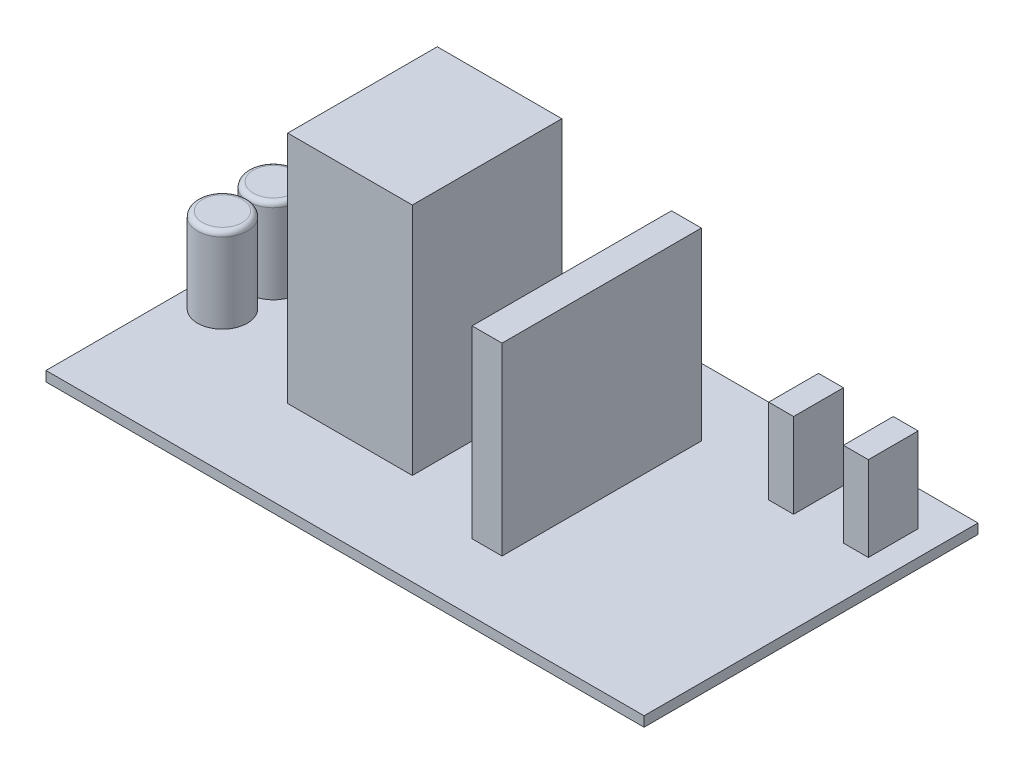
from build123d import *

# Parameters (mm, degrees)
SKETCH1_W           = 120
SKETCH1_H           = 67
BOSS_EXTRUDE1_DEPTH = 2
SKETCH2_R           = 5
BOSS_EXTRUDE2_DEPTH = 17
FILLET1_R           = 1
SKETCH3_W           = 25
SKETCH3_H           = 30
BOSS_EXTRUDE3_DEPTH = 47
SKETCH3_3_W         = 6
SKETCH3_3_H         = 40
BOSS_EXTRUDE4_DEPTH = 37
SKETCH3_4_W         = 5
SKETCH3_4_H         = 10
BOSS_EXTRUDE5_DEPTH = 17


with BuildPart() as part:
    # Sketch1 → Boss-Extrude1 (new body)
    with BuildSketch(Plane(origin=(0, 0, 0), x_dir=(1, 0, 0), z_dir=(0, 1, 0))):
        Rectangle(SKETCH1_W, SKETCH1_H)
    extrude(amount=BOSS_EXTRUDE1_DEPTH)

    # Sketch2 → Boss-Extrude2 (add)
    with BuildSketch(Plane(origin=(0, 2, 0), x_dir=(1, 0, 0), z_dir=(0, 1, 0))):
        with Locations((-53, 5.1)):
            Circle(SKETCH2_R)
        with Locations((-53, -5.1)):
            Circle(SKETCH2_R)
    extrude(amount=BOSS_EXTRUDE2_DEPTH)

    # Fillet1
    fillet1_edges = [part.edges().sort_by_distance(p)[0] for p in [
        (-58, 19, 5.1),
        (-58, 19, -5.1),
    ]]
    fillet(fillet1_edges, radius=FILLET1_R)

    # Sketch3 → Boss-Extrude3 (add)
    with BuildSketch(Plane(origin=(0, 2, 0), x_dir=(1, 0, 0), z_dir=(0, 1, 0))):
        with Locations((-17.5, 0)):
            Rectangle(SKETCH3_W, SKETCH3_H)
    extrude(amount=BOSS_EXTRUDE3_DEPTH)

    # Sketch3_3 → Boss-Extrude4 (add)
    with BuildSketch(Plane(origin=(0, 2, 0), x_dir=(1, 0, 0), z_dir=(0, 1, 0))):
        with Locations((15, 0)):
            Rectangle(SKETCH3_3_W, SKETCH3_3_H)
    extrude(amount=BOSS_EXTRUDE4_DEPTH)

    # Sketch3_4 → Boss-Extrude5 (add)
    with BuildSketch(Plane(origin=(0, 2, 0), x_dir=(1, 0, 0), z_dir=(0, 1, 0))):
        with Locations((52.5, 21.5)):
            Rectangle(SKETCH3_4_W, SKETCH3_4_H)
        with Locations((37.5, 21.5)):
            Rectangle(SKETCH3_4_W, SKETCH3_4_H)
    extrude(amount=BOSS_EXTRUDE5_DEPTH)


solid = part.part
